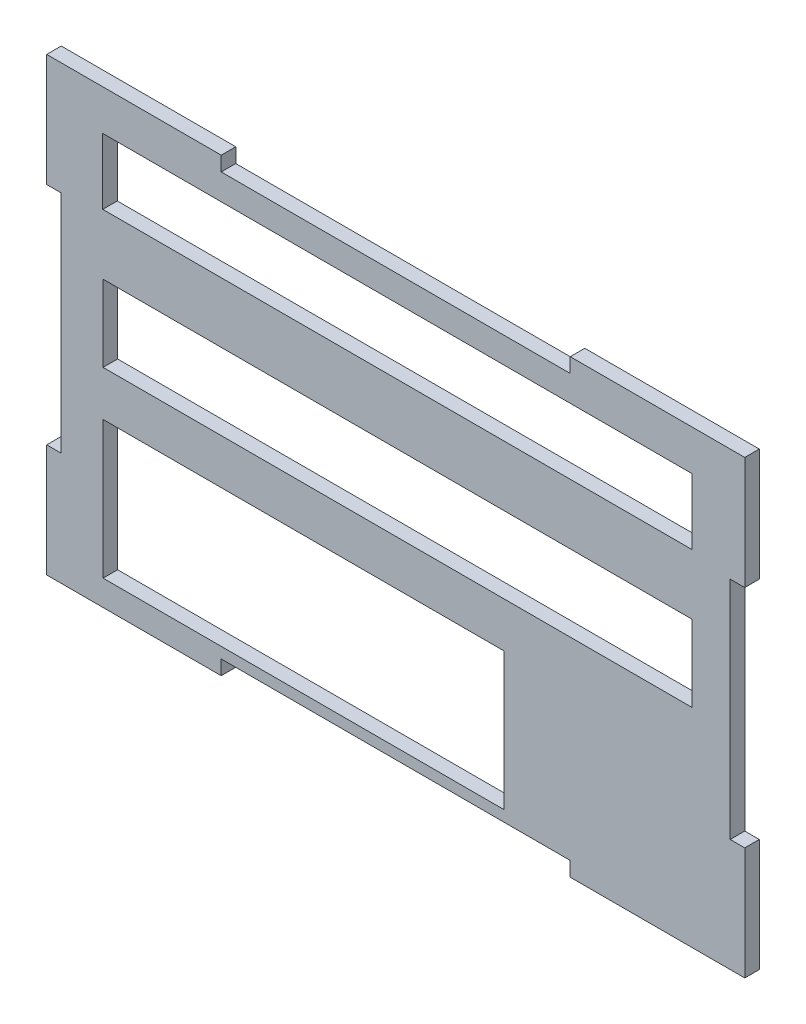
from build123d import *

# Parameters (mm, degrees)
SKETCH_1_W          = 96
SKETCH_1_H          = 62
EXTRUDE_1_DEPTH     = 2
SKETCH_2_W          = 55.125
SKETCH_2_H          = 18.9014
SKETCH_2_W_2        = 81
SKETCH_2_H_2        = 10.505077979
SKETCH_2_W_3        = 81.042070701
SKETCH_2_H_3        = 9.043475151
CUT_EXTRUDE_1_DEPTH = 2
SKETCH_3_W          = 48
SKETCH_3_H          = 2
CUT_EXTRUDE_2_DEPTH = 3
SKETCH_4_W          = 48
SKETCH_4_H          = 2
CUT_EXTRUDE_3_DEPTH = 3
SKETCH_5_W          = 2
SKETCH_5_H          = 31
CUT_EXTRUDE_4_DEPTH = 3
SKETCH_6_W          = 2
SKETCH_6_H          = 31
CUT_EXTRUDE_5_DEPTH = 3


with BuildPart() as part:
    # ｽｹｯﾁ1 → ﾎﾞｽ - 押し出し1 (new body)
    with BuildSketch(Plane.XY):
        with Locations((5.311186132, -2.735849057)):
            Rectangle(SKETCH_1_W, SKETCH_1_H)
    extrude(amount=EXTRUDE_1_DEPTH)

    # ｽｹｯﾁ2 → ｶｯﾄ - 押し出し1 (cut)
    with BuildSketch(Plane(origin=(0, 0, 0), x_dir=(-1, 0, 0), z_dir=(0, 0, -1))):
        with Locations((7.376313868, -20.786549057)):
            Rectangle(SKETCH_2_W, SKETCH_2_H)
        with Locations((-5.561186132, 0.116689932)):
            Rectangle(SKETCH_2_W_2, SKETCH_2_H_2)
        with Locations((-5.540150781, 18.185888519)):
            Rectangle(SKETCH_2_W_3, SKETCH_2_H_3)
    extrude(amount=-CUT_EXTRUDE_1_DEPTH, mode=Mode.SUBTRACT)

    # ｽｹｯﾁ3 → ｶｯﾄ - 押し出し2 (cut, through all)
    with BuildSketch(Plane(origin=(0, 0, 0), x_dir=(-1, 0, 0), z_dir=(0, 0, -1))):
        with Locations((-5.311186132, -32.735849057)):
            Rectangle(SKETCH_3_W, SKETCH_3_H)
    extrude(amount=-CUT_EXTRUDE_2_DEPTH, mode=Mode.SUBTRACT)

    # ｽｹｯﾁ4 → ｶｯﾄ - 押し出し3 (cut, through all)
    with BuildSketch(Plane(origin=(0, 0, 0), x_dir=(-1, 0, 0), z_dir=(0, 0, -1))):
        with Locations((-5.311186132, 27.264150943)):
            Rectangle(SKETCH_4_W, SKETCH_4_H)
    extrude(amount=-CUT_EXTRUDE_3_DEPTH, mode=Mode.SUBTRACT)

    # ｽｹｯﾁ5 → ｶｯﾄ - 押し出し4 (cut, through all)
    with BuildSketch(Plane(origin=(0, 0, 0), x_dir=(-1, 0, 0), z_dir=(0, 0, -1))):
        with Locations((41.688813868, -2.735849057)):
            Rectangle(SKETCH_5_W, SKETCH_5_H)
    extrude(amount=-CUT_EXTRUDE_4_DEPTH, mode=Mode.SUBTRACT)

    # ｽｹｯﾁ6 → ｶｯﾄ - 押し出し5 (cut, through all)
    with BuildSketch(Plane(origin=(0, 0, 0), x_dir=(-1, 0, 0), z_dir=(0, 0, -1))):
        with Locations((-52.311186132, -2.735849057)):
            Rectangle(SKETCH_6_W, SKETCH_6_H)
    extrude(amount=-CUT_EXTRUDE_5_DEPTH, mode=Mode.SUBTRACT)


solid = part.part
